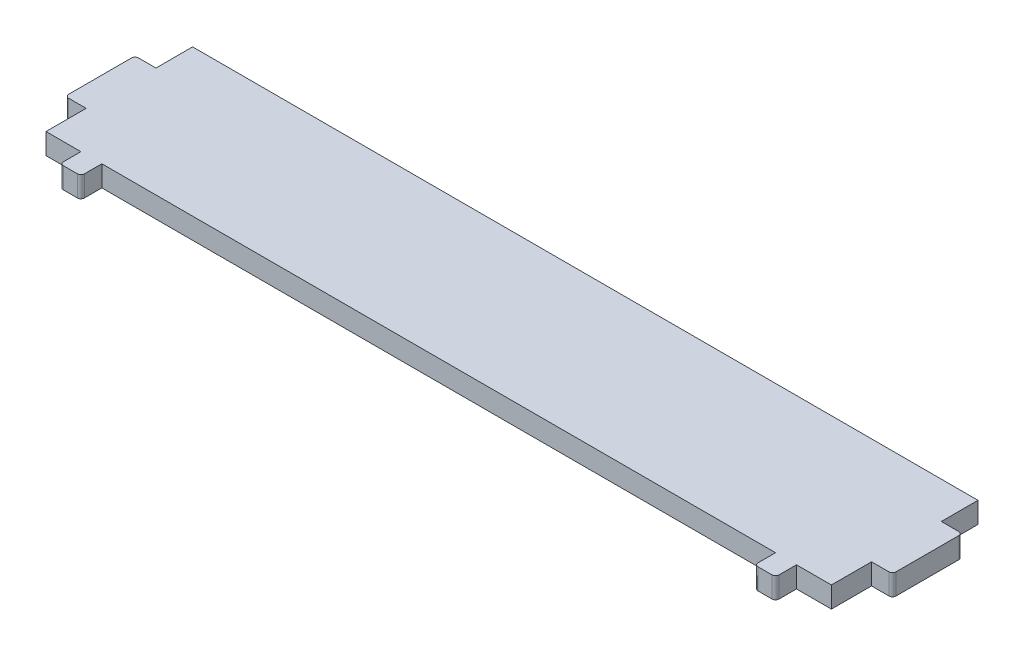
from build123d import *

# Parameters (mm, degrees)
SKETCH_1_W      = 3
SKETCH_1_H      = 3
EXTRUDE_1_DEPTH = 3
FILLET_1_R      = 0.5


with BuildPart() as part:
    # Эскиз1 → Бобышка-Вытянуть1 (new body)
    with BuildSketch(Plane(origin=(0, 0, 0), x_dir=(1, 0, 0), z_dir=(0, 1, 0))):
        Polygon((-56.25, -21), (56.25, -21), (56.25, -15.25), (59.25, -15.25), (59.25, -5.25), (56.25, -5.25), (56.25, 0), (-56.25, 0), (-56.25, -5.25), (-59.25, -5.25), (-59.25, -15.25), (-56.25, -15.25), align=None)
        with Locations((49.75, -22.5)):
            Rectangle(SKETCH_1_W, SKETCH_1_H)
        with Locations((-49.75, -22.5)):
            Rectangle(SKETCH_1_W, SKETCH_1_H)
    extrude(amount=EXTRUDE_1_DEPTH)

    # Скругление1
    fillet_1_edges = [part.edges().sort_by_distance(p)[0] for p in [
        (-59.25, 1.5, 15.25),
        (-59.25, 1.5, 5.25),
        (59.25, 1.5, 5.25),
        (59.25, 1.5, 15.25),
        (51.25, 1.5, 24),
        (48.25, 1.5, 24),
        (-48.25, 1.5, 24),
        (-51.25, 1.5, 24),
    ]]
    fillet(fillet_1_edges, radius=FILLET_1_R)


solid = part.part
